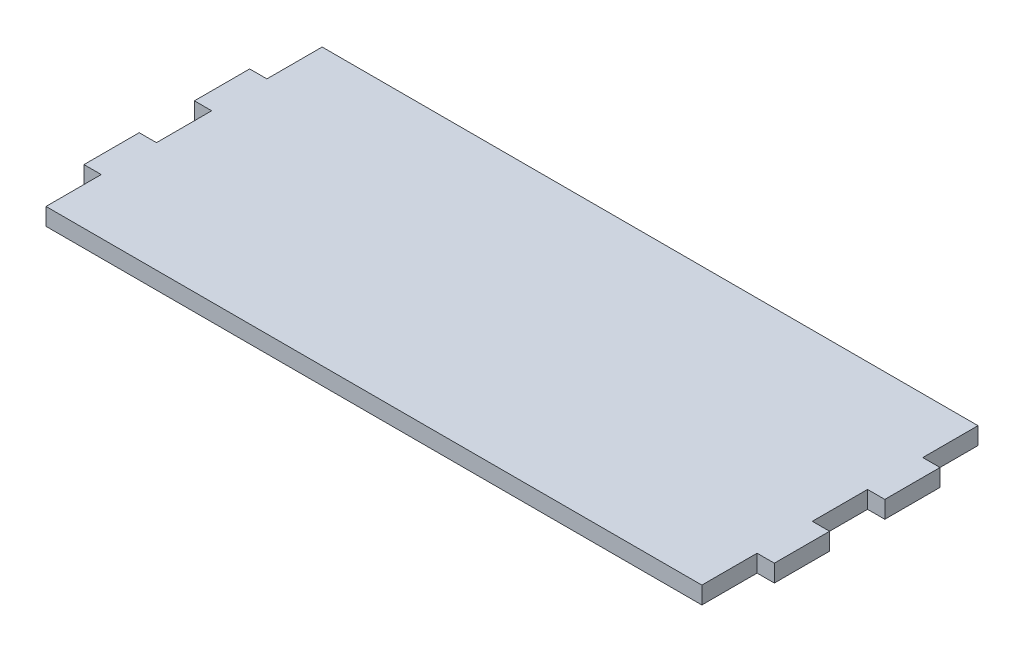
from build123d import *

# Parameters (mm, degrees)
BOSS_EXTRUDE1_DEPTH = 5


with BuildPart() as part:
    # Sketch1 → Boss-Extrude1 (new body)
    with BuildSketch(Plane(origin=(0, 0, 0), x_dir=(1, 0, 0), z_dir=(0, 1, 0))):
        Polygon((-122.5, 40), (-122.5, 24), (-127.5, 24), (-127.5, 8), (-122.5, 8), (-122.5, -8), (-127.5, -8), (-127.5, -24), (-122.5, -24), (-122.5, -40), (67.5, -40), (67.5, -24), (72.5, -24), (72.5, -8), (67.5, -8), (67.5, 8), (72.5, 8), (72.5, 24), (67.5, 24), (67.5, 40), align=None)
    extrude(amount=BOSS_EXTRUDE1_DEPTH)


solid = part.part
